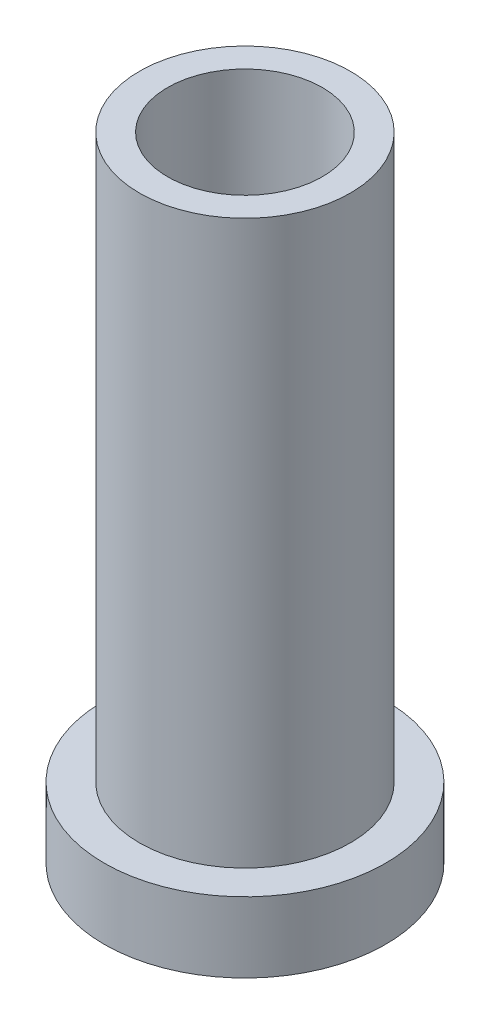
from build123d import *

# Parameters (mm, degrees)
SKETCH1_R           = 10
BOSS_EXTRUDE1_DEPTH = 2.5
SKETCH2_R           = 7.5
BOSS_EXTRUDE2_DEPTH = 40
SKETCH3_R           = 5.5
CUT_EXTRUDE1_DEPTH  = 46


with BuildPart() as part:
    # Sketch1 → Boss-Extrude1 (new body, symmetric)
    with BuildSketch(Plane(origin=(0, 0, 0), x_dir=(1, 0, 0), z_dir=(0, 1, 0))):
        Circle(SKETCH1_R)
    extrude(amount=BOSS_EXTRUDE1_DEPTH, both=True)

    # Sketch2 → Boss-Extrude2 (add)
    with BuildSketch(Plane(origin=(0, 2.5, 0), x_dir=(1, 0, 0), z_dir=(0, 1, 0))):
        Circle(SKETCH2_R)
    extrude(amount=BOSS_EXTRUDE2_DEPTH)

    # Sketch3 → Cut-Extrude1 (cut, through all)
    with BuildSketch(Plane(origin=(0, -2.5, 0), x_dir=(-1, 0, 0), z_dir=(0, -1, 0))):
        Circle(SKETCH3_R)
    extrude(amount=-CUT_EXTRUDE1_DEPTH, mode=Mode.SUBTRACT)


solid = part.part
